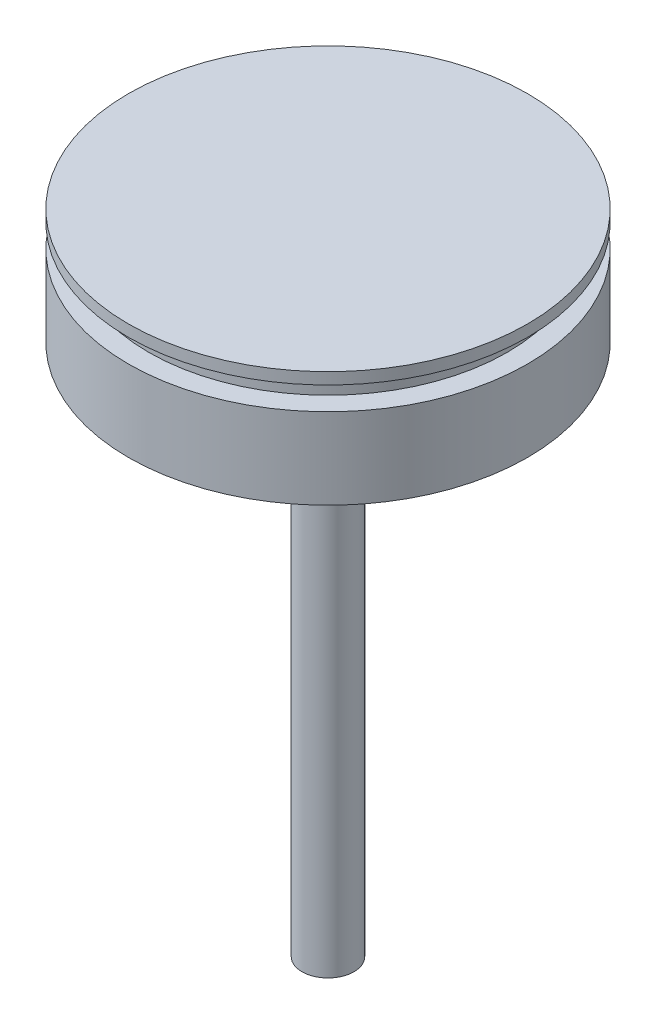
from build123d import *

# Parameters (mm, degrees)
SKETCH2_R           = 4.5
BOSS_EXTRUDE1_DEPTH = 92


with BuildPart() as part:
    # Sketch1 → Revolve1 (revolve)
    with BuildSketch(Plane(origin=(0, 0, 0), x_dir=(0, 0, -1), z_dir=(1, 0, 0))):
        Polygon((0, 0), (34.5, 0), (34.5, -2), (31, -2), (31, -6), (34.5, -6), (34.5, -14), (34.5, -18), (34.5, -20), (0, -20), align=None)
    revolve(axis=Axis((0, -20, 0), (0, 1, 0)))

    # Sketch2 → Boss-Extrude1 (add)
    with BuildSketch(Plane.XZ.offset(20)):
        Circle(SKETCH2_R)
    extrude(amount=BOSS_EXTRUDE1_DEPTH)


solid = part.part
